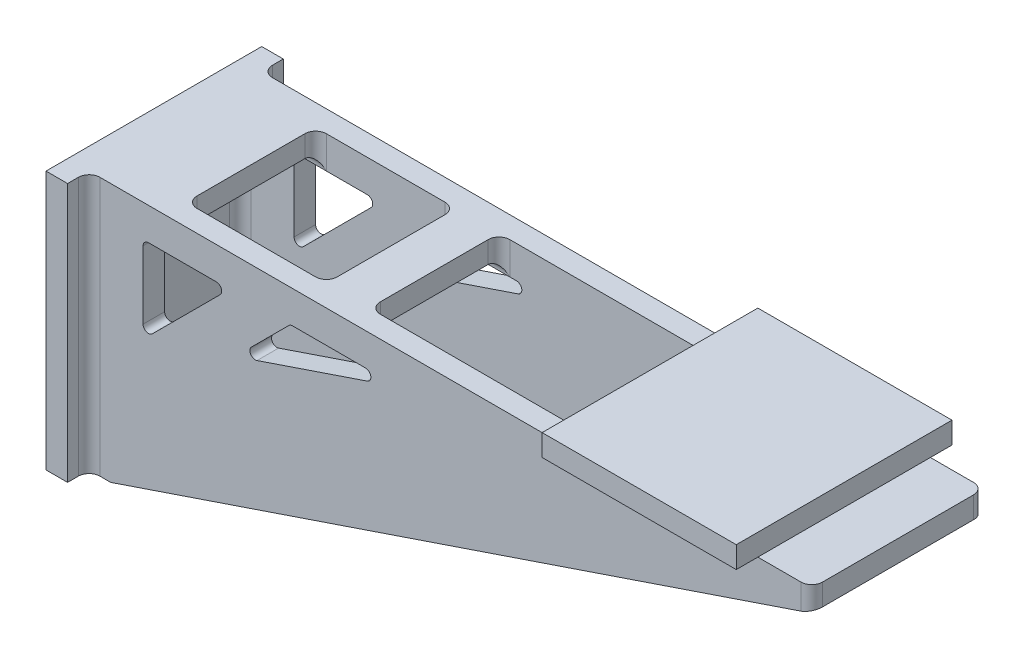
from build123d import *

# Parameters (mm, degrees)
BASE_SKETCH_W            = 254
BASE_SKETCH_H            = 304.8
BASE_DEPTH               = 25.4
RIGHT_TRIANGLE_DEPTH     = 25.4
LEFT_TRIANGLE_DEPTH      = 25.4
SUPPORT_BEAMS_SKETCH_W   = 114.3
SUPPORT_BEAMS_SKETCH_H   = 203.2
SUPPORT_BEAMS_SKETCH_W_2 = 50.8
SUPPORT_BEAMS_SKETCH_W_3 = 88.9
SUPPORT_BEAMS_DEPTH      = 25.4
FILLET1_R                = 12.7
TOP_PLATE_SKETCH_W       = 228.6
TOP_PLATE_SKETCH_H       = 254
TOP_PLATE_DEPTH          = 25.4
FILLET4_R                = 2.54
CUT_EXTRUDE1_DEPTH       = 229.6
FILLET6_R                = 6.35


with BuildPart() as part:
    # Base Sketch → Base (new body)
    with BuildSketch(Plane(origin=(0, 0, 0), x_dir=(0, 0, -1), z_dir=(1, 0, 0))):
        Rectangle(BASE_SKETCH_W, BASE_SKETCH_H)
    extrude(amount=BASE_DEPTH)

    # Right Triangle Sketch → Right Triangle (add)
    with BuildSketch(Plane.XY.offset(101.6)):
        Polygon((0, 152.4), (876.3, 152.4), (876.3, 127), (50.8, -152.4), (0, -152.4), align=None)
    extrude(amount=-RIGHT_TRIANGLE_DEPTH)

    # Left Triangle Sketch → Left Triangle (add)
    with BuildSketch(Plane(origin=(0, 0, -101.6), x_dir=(-1, 0, 0), z_dir=(0, 0, -1))):
        Polygon((0, 152.4), (-876.3, 152.4), (-876.3, 127), (-50.8, -152.4), (0, -152.4), align=None)
    extrude(amount=-LEFT_TRIANGLE_DEPTH)

    # Support Beams Sketch → Support Beams (add)
    with BuildSketch(Plane(origin=(0, 152.4, 0), x_dir=(1, 0, 0), z_dir=(0, 1, 0))):
        with Locations((57.15, 0)):
            Rectangle(SUPPORT_BEAMS_SKETCH_W, SUPPORT_BEAMS_SKETCH_H)
        with Locations((304.8, 0)):
            Rectangle(SUPPORT_BEAMS_SKETCH_W_2, SUPPORT_BEAMS_SKETCH_H)
        with Locations((831.85, 0)):
            Rectangle(SUPPORT_BEAMS_SKETCH_W_3, SUPPORT_BEAMS_SKETCH_H)
    extrude(amount=-SUPPORT_BEAMS_DEPTH)

    # Fillet1
    fillet1_edges = [part.edges().sort_by_distance(p)[0] for p in [
        (279.4, 139.7, 76.2),
        (330.2, 139.7, 76.2),
        (304.8, 127, 76.2),
        (304.8, 127, -76.2),
        (279.4, 139.7, -76.2),
        (330.2, 139.7, -76.2),
        (787.4, 139.7, 76.2),
        (831.85, 127, 76.2),
        (831.85, 127, -76.2),
        (787.4, 139.7, -76.2),
        (25.4, 0, 101.6),
        (876.3, 139.7, 101.6),
        (876.3, 139.7, -101.6),
        (25.4, 0, -101.6),
        (25.4, -12.7, -76.2),
        (25.4, -12.7, 76.2),
        (114.3, 139.7, 76.2),
        (69.85, 127, 76.2),
        (114.3, 139.7, -76.2),
        (25.4, 127, 0),
        (69.85, 127, -76.2),
    ]]
    fillet(fillet1_edges, radius=FILLET1_R)

    # Top Plate Sketch → Top Plate (add)
    with BuildSketch(Plane(origin=(0, 152.4, 0), x_dir=(1, 0, 0), z_dir=(0, 1, 0))):
        with Locations((698.5, 0)):
            Rectangle(TOP_PLATE_SKETCH_W, TOP_PLATE_SKETCH_H)
    extrude(amount=TOP_PLATE_DEPTH)

    # Fillet4
    fillet4_edges = [part.edges().sort_by_distance(p)[0] for p in [
        (787.4, 152.4, 0),
        (679.45, 152.4, 76.2),
        (783.680256121, 152.4, 72.480256121),
        (783.680256121, 152.4, -72.480256121),
        (679.45, 152.4, -76.2),
    ]]
    fillet(fillet4_edges, radius=FILLET4_R)

    # Sketch1 → Cut-Extrude1 (cut, through all)
    with BuildSketch(Plane.XY.offset(101.6)):
        Polygon((88.9, 12.7), (88.9, 114.3), (190.5, 114.3), align=None)
        Polygon((197.365304783, 49.323255814), (262.342048969, 114.3), (389.342048969, 114.3), align=None)
    extrude(amount=-CUT_EXTRUDE1_DEPTH, mode=Mode.SUBTRACT)

    # Fillet6
    fillet6_edges = [part.edges().sort_by_distance(p)[0] for p in [
        (190.5, 114.3, -88.9),
        (88.9, 12.7, -88.9),
        (88.9, 114.3, -88.9),
        (190.5, 114.3, 88.9),
        (88.9, 12.7, 88.9),
        (88.9, 114.3, 88.9),
        (389.342048969, 114.3, -88.9),
        (197.365304783, 49.323255814, -88.9),
        (262.342048969, 114.3, -88.9),
        (389.342048969, 114.3, 88.9),
        (197.365304783, 49.323255814, 88.9),
        (262.342048969, 114.3, 88.9),
    ]]
    fillet(fillet6_edges, radius=FILLET6_R)


solid = part.part
